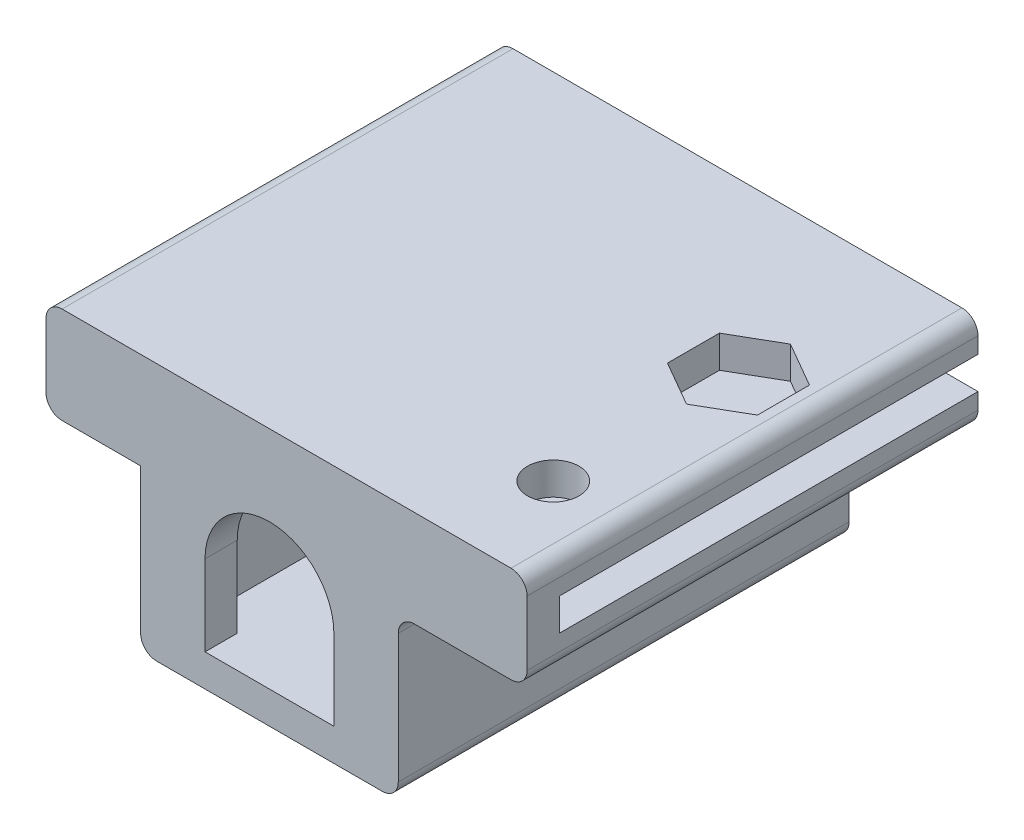
from build123d import *

# Parameters (mm, degrees)
EXTRUDE_1_DEPTH          = 2
EXTRUDE_2_DEPTH          = 26
SKETCH_3_W               = 12
SKETCH_3_H               = 1
EXTRUDE_3_DEPTH          = 1.6
CUT_EXTRUDE_1_DEPTH      = 2
CUT_EXTRUDE_2_DEPTH      = 11
CUT_EXTRUDE_2_DEPTH_BACK = 0.5
CUT_EXTRUDE_3_DEPTH      = 11
CUT_EXTRUDE_3_DEPTH_BACK = 1
SKETCH_7_R               = 1.35
SKETCH_7_R_2             = 1.6
CUT_EXTRUDE_4_DEPTH      = 1
CUT_EXTRUDE_4_DEPTH_BACK = 6


with BuildPart() as part:
    # 草图1 → 凸台-拉伸1 (new body)
    with BuildSketch(Plane.XY):
        with BuildLine():
            ThreePointArc((8, 2), (8.292893219, 2.707106781), (9, 3))
            Line((9, 3), (15, 3))
            ThreePointArc((15, 3), (15.707106781, 3.292893219), (16, 4))
            Line((16, 4), (16, 8))
            ThreePointArc((16, 8), (15.707106781, 8.707106781), (15, 9))
            Line((15, 9), (-12.875, 9))
            ThreePointArc((-12.875, 9), (-13.582106781, 8.707106781), (-13.875, 8))
            Line((-13.875, 8), (-13.875, 4))
            ThreePointArc((-13.875, 4), (-13.582106781, 3.292893219), (-12.875, 3))
            Line((-12.875, 3), (-8, 3))
            Line((-8, 3), (-8, -6))
            ThreePointArc((-8, -6), (-7.707106781, -6.707106781), (-7, -7))
            Line((-7, -7), (7, -7))
            ThreePointArc((7, -7), (7.707106781, -6.707106781), (8, -6))
            Line((8, -6), (8, 2))
        make_face()
        with BuildLine():
            Line((4, -5), (-4, -5))
            Line((-4, -5), (-4, 0))
            ThreePointArc((-4, 0), (0, 4), (4, 0))
            Line((4, 0), (4, -5))
        make_face(mode=Mode.SUBTRACT)
    extrude(amount=EXTRUDE_1_DEPTH)

    # 草图2 → 凸台-拉伸2 (add)
    with BuildSketch(Plane(origin=(0, 0, 0), x_dir=(-1, 0, 0), z_dir=(0, 0, -1))):
        with BuildLine():
            Line((6, -4), (6, -5))
            Line((6, -5), (5, -5))
            Line((5, -5), (-5, -5))
            Line((-5, -5), (-6, -5))
            Line((-6, -5), (-6, -4))
            Line((-6, -4), (-6, 4))
            Line((-6, 4), (-6, 5))
            Line((-6, 5), (-16, 5))
            Line((-16, 5), (-16, 4))
            ThreePointArc((-16, 4), (-15.707106781, 3.292893219), (-15, 3))
            Line((-15, 3), (-9, 3))
            ThreePointArc((-9, 3), (-8.292893219, 2.707106781), (-8, 2))
            Line((-8, 2), (-8, -6))
            ThreePointArc((-8, -6), (-7.707106781, -6.707106781), (-7, -7))
            Line((-7, -7), (7, -7))
            ThreePointArc((7, -7), (7.707106781, -6.707106781), (8, -6))
            Line((8, -6), (8, 3))
            Line((8, 3), (12.875, 3))
            ThreePointArc((12.875, 3), (13.582106781, 3.292893219), (13.875, 4))
            Line((13.875, 4), (13.875, 8))
            ThreePointArc((13.875, 8), (13.582106781, 8.707106781), (12.875, 9))
            Line((12.875, 9), (-15, 9))
            ThreePointArc((-15, 9), (-15.707106781, 8.707106781), (-16, 8))
            Line((-16, 8), (-16, 7))
            Line((-16, 7), (11.875, 7))
            Line((11.875, 7), (11.875, 5))
            Line((11.875, 5), (6, 5))
            Line((6, 5), (6, 4))
            Line((6, 4), (6, -4))
        make_face()
    extrude(amount=EXTRUDE_2_DEPTH)

    # 草图3 → 凸台-拉伸3 (add)
    with BuildSketch(Plane(origin=(0, 0, -26), x_dir=(-1, 0, 0), z_dir=(0, 0, -1))):
        with Locations((0, -4.5)):
            Rectangle(SKETCH_3_W, SKETCH_3_H)
    extrude(amount=-EXTRUDE_3_DEPTH)

    # 草图4 → 切除-拉伸1 (cut)
    with BuildSketch(Plane(origin=(0, 9, 0), x_dir=(1, 0, 0), z_dir=(0, 1, 0))):
        Polygon((11.625, 12.272649731), (14.41996732, 13.886324865), (14.41996732, 17.113675135), (11.625, 18.727350269), (8.83003268, 17.113675135), (8.83003268, 13.886324865), align=None)
    extrude(amount=-CUT_EXTRUDE_1_DEPTH, mode=Mode.SUBTRACT)

    # 草图5 → 切除-拉伸2 (cut, two sides)
    with BuildSketch(Plane.XZ.offset(-3)) as cut_extrude_2_sk:
        Polygon((11.625, -18.675426481), (14.375, -17.08771324), (14.375, -13.91228676), (11.625, -12.324573519), (8.875, -13.91228676), (8.875, -17.08771324), align=None)
    extrude(amount=CUT_EXTRUDE_2_DEPTH, mode=Mode.SUBTRACT)
    extrude(cut_extrude_2_sk.sketch, amount=-CUT_EXTRUDE_2_DEPTH_BACK, mode=Mode.SUBTRACT)

    # 草图6 → 切除-拉伸3 (cut, two sides)
    with BuildSketch(Plane.XZ.offset(-3)) as cut_extrude_3_sk:
        Polygon((8.625, -5.732050808), (11.625, -7.464101615), (14.625, -5.732050808), (14.625, -2.267949192), (11.625, -0.535898385), (8.625, -2.267949192), align=None)
    extrude(amount=CUT_EXTRUDE_3_DEPTH, mode=Mode.SUBTRACT)
    extrude(cut_extrude_3_sk.sketch, amount=-CUT_EXTRUDE_3_DEPTH_BACK, mode=Mode.SUBTRACT)

    # 草图7 → 切除-拉伸4 (cut, two sides)
    with BuildSketch(Plane.XZ.offset(-4)) as cut_extrude_4_sk:
        with Locations((11.625, -15.5)):
            Circle(SKETCH_7_R)
        with Locations((11.625, -4)):
            Circle(SKETCH_7_R_2)
    extrude(amount=CUT_EXTRUDE_4_DEPTH, mode=Mode.SUBTRACT)
    extrude(cut_extrude_4_sk.sketch, amount=-CUT_EXTRUDE_4_DEPTH_BACK, mode=Mode.SUBTRACT)


solid = part.part
